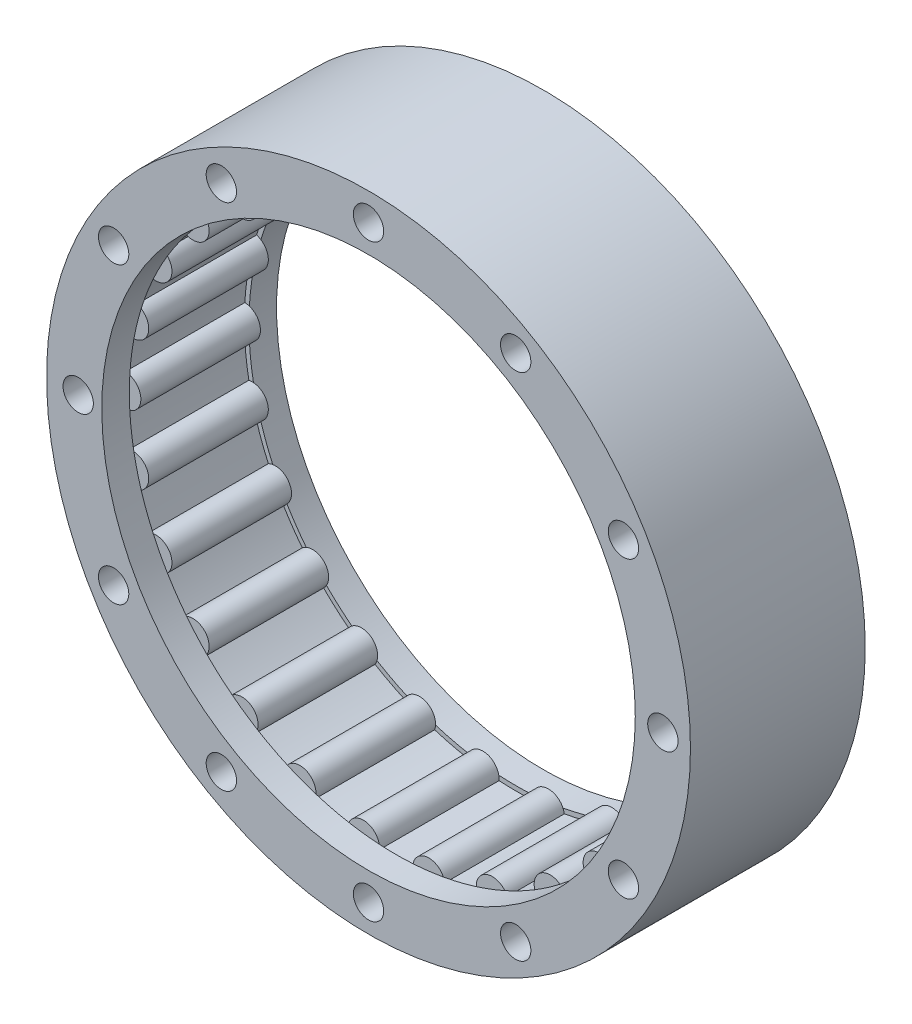
from build123d import *

# Parameters (mm, degrees)
SKETCH_1_R          = 35
SKETCH_1_R_2        = 29.5
EXTRUDE_1_DEPTH     = 13
SKETCH_2_R          = 1.75
EXTRUDE_2_DEPTH     = 13
EXTRUDE_2_2_DEPTH   = 13
EXTRUDE_2_3_DEPTH   = 13
EXTRUDE_2_4_DEPTH   = 13
EXTRUDE_2_5_DEPTH   = 13
EXTRUDE_2_6_DEPTH   = 13
EXTRUDE_2_7_DEPTH   = 13
EXTRUDE_2_8_DEPTH   = 13
EXTRUDE_2_9_DEPTH   = 13
EXTRUDE_2_10_DEPTH  = 13
EXTRUDE_2_11_DEPTH  = 13
EXTRUDE_2_12_DEPTH  = 13
EXTRUDE_2_13_DEPTH  = 13
EXTRUDE_2_14_DEPTH  = 13
EXTRUDE_2_15_DEPTH  = 13
EXTRUDE_2_16_DEPTH  = 13
EXTRUDE_2_17_DEPTH  = 13
EXTRUDE_2_18_DEPTH  = 13
EXTRUDE_2_19_DEPTH  = 13
EXTRUDE_2_20_DEPTH  = 13
EXTRUDE_2_21_DEPTH  = 13
EXTRUDE_2_22_DEPTH  = 13
EXTRUDE_2_23_DEPTH  = 13
EXTRUDE_2_24_DEPTH  = 13
EXTRUDE_2_25_DEPTH  = 13
EXTRUDE_2_26_DEPTH  = 13
SKETCH_14_R         = 35
SKETCH_14_R_2       = 29
EXTRUDE_3_DEPTH     = 3
SKETCH_17_R         = 35
SKETCH_17_R_2       = 29
EXTRUDE_4_DEPTH     = 3
SKETCH_18_R         = 1.65
CUT_EXTRUDE_2_DEPTH = 20


with BuildPart() as part:
    # 草图1 → 凸台-拉伸1 (new body)
    with BuildSketch(Plane.XY):
        Circle(SKETCH_1_R)
        Circle(SKETCH_1_R_2, mode=Mode.SUBTRACT)
    extrude(amount=EXTRUDE_1_DEPTH)



with BuildPart() as body_2:
    # 草图2 → 凸台-拉伸2 (new body)
    with BuildSketch(Plane.XY.offset(13)):
        with Locations((29.5, 0)):
            Circle(SKETCH_2_R)
    extrude(amount=-EXTRUDE_2_DEPTH)


with BuildPart() as body_3:
    # 草图2 → Extrude 2 2 (new body)
    with BuildSketch(Plane.XY.offset(13)):
        with Locations((28.642783614, -7.059812096)):
            Circle(SKETCH_2_R)
    extrude(amount=-EXTRUDE_2_2_DEPTH)


with BuildPart() as body_4:
    # 草图2 → Extrude 2 3 (new body)
    with BuildSketch(Plane.XY.offset(13)):
        with Locations((26.120952757, -13.709333575)):
            Circle(SKETCH_2_R)
    extrude(amount=-EXTRUDE_2_3_DEPTH)


with BuildPart() as body_5:
    # 草图2 → Extrude 2 4 (new body)
    with BuildSketch(Plane.XY.offset(13)):
        with Locations((22.081067071, -19.562118418)):
            Circle(SKETCH_2_R)
    extrude(amount=-EXTRUDE_2_4_DEPTH)


with BuildPart() as body_6:
    # 草图2 → Extrude 2 5 (new body)
    with BuildSketch(Plane.XY.offset(13)):
        with Locations((16.757910029, -24.278024044)):
            Circle(SKETCH_2_R)
    extrude(amount=-EXTRUDE_2_5_DEPTH)


with BuildPart() as body_7:
    # 草图2 → Extrude 2 6 (new body)
    with BuildSketch(Plane.XY.offset(13)):
        with Locations((10.460844168, -27.582979159)):
            Circle(SKETCH_2_R)
    extrude(amount=-EXTRUDE_2_6_DEPTH)


with BuildPart() as body_8:
    # 草图2 → Extrude 2 7 (new body)
    with BuildSketch(Plane.XY.offset(13)):
        with Locations((3.555832068, -29.284911786)):
            Circle(SKETCH_2_R)
    extrude(amount=-EXTRUDE_2_7_DEPTH)


with BuildPart() as body_9:
    # 草图2 → Extrude 2 8 (new body)
    with BuildSketch(Plane.XY.offset(13)):
        with Locations((-3.555832068, -29.284911786)):
            Circle(SKETCH_2_R)
    extrude(amount=-EXTRUDE_2_8_DEPTH)


with BuildPart() as body_10:
    # 草图2 → Extrude 2 9 (new body)
    with BuildSketch(Plane.XY.offset(13)):
        with Locations((-10.460844168, -27.582979159)):
            Circle(SKETCH_2_R)
    extrude(amount=-EXTRUDE_2_9_DEPTH)


with BuildPart() as body_11:
    # 草图2 → Extrude 2 10 (new body)
    with BuildSketch(Plane.XY.offset(13)):
        with Locations((-16.757910029, -24.278024044)):
            Circle(SKETCH_2_R)
    extrude(amount=-EXTRUDE_2_10_DEPTH)


with BuildPart() as body_12:
    # 草图2 → Extrude 2 11 (new body)
    with BuildSketch(Plane.XY.offset(13)):
        with Locations((-22.081067071, -19.562118418)):
            Circle(SKETCH_2_R)
    extrude(amount=-EXTRUDE_2_11_DEPTH)


with BuildPart() as body_13:
    # 草图2 → Extrude 2 12 (new body)
    with BuildSketch(Plane.XY.offset(13)):
        with Locations((-26.120952757, -13.709333575)):
            Circle(SKETCH_2_R)
    extrude(amount=-EXTRUDE_2_12_DEPTH)


with BuildPart() as body_14:
    # 草图2 → Extrude 2 13 (new body)
    with BuildSketch(Plane.XY.offset(13)):
        with Locations((-28.642783614, -7.059812096)):
            Circle(SKETCH_2_R)
    extrude(amount=-EXTRUDE_2_13_DEPTH)


with BuildPart() as body_15:
    # 草图2 → Extrude 2 14 (new body)
    with BuildSketch(Plane.XY.offset(13)):
        with Locations((-29.5, 0)):
            Circle(SKETCH_2_R)
    extrude(amount=-EXTRUDE_2_14_DEPTH)


with BuildPart() as body_16:
    # 草图2 → Extrude 2 15 (new body)
    with BuildSketch(Plane.XY.offset(13)):
        with Locations((-28.642783614, 7.059812096)):
            Circle(SKETCH_2_R)
    extrude(amount=-EXTRUDE_2_15_DEPTH)


with BuildPart() as body_17:
    # 草图2 → Extrude 2 16 (new body)
    with BuildSketch(Plane.XY.offset(13)):
        with Locations((-26.120952757, 13.709333575)):
            Circle(SKETCH_2_R)
    extrude(amount=-EXTRUDE_2_16_DEPTH)


with BuildPart() as body_18:
    # 草图2 → Extrude 2 17 (new body)
    with BuildSketch(Plane.XY.offset(13)):
        with Locations((-22.081067071, 19.562118418)):
            Circle(SKETCH_2_R)
    extrude(amount=-EXTRUDE_2_17_DEPTH)


with BuildPart() as body_19:
    # 草图2 → Extrude 2 18 (new body)
    with BuildSketch(Plane.XY.offset(13)):
        with Locations((-16.757910029, 24.278024044)):
            Circle(SKETCH_2_R)
    extrude(amount=-EXTRUDE_2_18_DEPTH)


with BuildPart() as body_20:
    # 草图2 → Extrude 2 19 (new body)
    with BuildSketch(Plane.XY.offset(13)):
        with Locations((-10.460844168, 27.582979159)):
            Circle(SKETCH_2_R)
    extrude(amount=-EXTRUDE_2_19_DEPTH)


with BuildPart() as body_21:
    # 草图2 → Extrude 2 20 (new body)
    with BuildSketch(Plane.XY.offset(13)):
        with Locations((-3.555832068, 29.284911786)):
            Circle(SKETCH_2_R)
    extrude(amount=-EXTRUDE_2_20_DEPTH)


with BuildPart() as body_22:
    # 草图2 → Extrude 2 21 (new body)
    with BuildSketch(Plane.XY.offset(13)):
        with Locations((3.555832068, 29.284911786)):
            Circle(SKETCH_2_R)
    extrude(amount=-EXTRUDE_2_21_DEPTH)


with BuildPart() as body_23:
    # 草图2 → Extrude 2 22 (new body)
    with BuildSketch(Plane.XY.offset(13)):
        with Locations((10.460844168, 27.582979159)):
            Circle(SKETCH_2_R)
    extrude(amount=-EXTRUDE_2_22_DEPTH)


with BuildPart() as body_24:
    # 草图2 → Extrude 2 23 (new body)
    with BuildSketch(Plane.XY.offset(13)):
        with Locations((16.757910029, 24.278024044)):
            Circle(SKETCH_2_R)
    extrude(amount=-EXTRUDE_2_23_DEPTH)


with BuildPart() as body_25:
    # 草图2 → Extrude 2 24 (new body)
    with BuildSketch(Plane.XY.offset(13)):
        with Locations((22.081067071, 19.562118418)):
            Circle(SKETCH_2_R)
    extrude(amount=-EXTRUDE_2_24_DEPTH)


with BuildPart() as body_26:
    # 草图2 → Extrude 2 25 (new body)
    with BuildSketch(Plane.XY.offset(13)):
        with Locations((26.120952757, 13.709333575)):
            Circle(SKETCH_2_R)
    extrude(amount=-EXTRUDE_2_25_DEPTH)


with BuildPart() as body_27:
    # 草图2 → Extrude 2 26 (new body)
    with BuildSketch(Plane.XY.offset(13)):
        with Locations((28.642783614, 7.059812096)):
            Circle(SKETCH_2_R)
    extrude(amount=-EXTRUDE_2_26_DEPTH)


with BuildPart() as part_1:
    add(part.part)

    add(body_2.part)  # 凸台-拉伸3 merges body 2

    add(body_3.part)  # 凸台-拉伸3 merges body 3

    add(body_4.part)  # 凸台-拉伸3 merges body 4

    add(body_5.part)  # 凸台-拉伸3 merges body 5

    add(body_6.part)  # 凸台-拉伸3 merges body 6

    add(body_7.part)  # 凸台-拉伸3 merges body 7

    add(body_8.part)  # 凸台-拉伸3 merges body 8

    add(body_9.part)  # 凸台-拉伸3 merges body 9

    add(body_10.part)  # 凸台-拉伸3 merges body 10

    add(body_11.part)  # 凸台-拉伸3 merges body 11

    add(body_12.part)  # 凸台-拉伸3 merges body 12

    add(body_13.part)  # 凸台-拉伸3 merges body 13

    add(body_14.part)  # 凸台-拉伸3 merges body 14

    add(body_15.part)  # 凸台-拉伸3 merges body 15

    add(body_16.part)  # 凸台-拉伸3 merges body 16

    add(body_17.part)  # 凸台-拉伸3 merges body 17

    add(body_18.part)  # 凸台-拉伸3 merges body 18

    add(body_19.part)  # 凸台-拉伸3 merges body 19

    add(body_20.part)  # 凸台-拉伸3 merges body 20

    add(body_21.part)  # 凸台-拉伸3 merges body 21

    add(body_22.part)  # 凸台-拉伸3 merges body 22

    add(body_23.part)  # 凸台-拉伸3 merges body 23

    add(body_24.part)  # 凸台-拉伸3 merges body 24

    add(body_25.part)  # 凸台-拉伸3 merges body 25

    add(body_26.part)  # 凸台-拉伸3 merges body 26

    add(body_27.part)  # 凸台-拉伸3 merges body 27
    # 草图14 → 凸台-拉伸3 (add)
    with BuildSketch(Plane.XY):
        Circle(SKETCH_14_R)
        Circle(SKETCH_14_R_2, mode=Mode.SUBTRACT)
    extrude(amount=-EXTRUDE_3_DEPTH)

    # 草图17 → 凸台-拉伸4 (add)
    with BuildSketch(Plane.XY.offset(13)):
        Circle(SKETCH_17_R)
        Circle(SKETCH_17_R_2, mode=Mode.SUBTRACT)
    extrude(amount=EXTRUDE_4_DEPTH)

    # 草图18 → 切除-拉伸2 (cut, through all)
    with BuildSketch(Plane(origin=(0, 0, -3), x_dir=(-1, 0, 0), z_dir=(0, 0, -1))):
        with Locations((31.56394508, 0)):
            Circle(SKETCH_18_R)
        with Locations((27.712812921, -16)):
            Circle(SKETCH_18_R)
        with Locations((16, -27.712812921)):
            Circle(SKETCH_18_R)
        with Locations((0, -32)):
            Circle(SKETCH_18_R)
        with Locations((-16, -27.712812921)):
            Circle(SKETCH_18_R)
        with Locations((-27.712812921, -16)):
            Circle(SKETCH_18_R)
        with Locations((-32, 0)):
            Circle(SKETCH_18_R)
        with Locations((-27.712812921, 16)):
            Circle(SKETCH_18_R)
        with Locations((-16, 27.712812921)):
            Circle(SKETCH_18_R)
        with Locations((0, 32)):
            Circle(SKETCH_18_R)
        with Locations((16, 27.712812921)):
            Circle(SKETCH_18_R)
        with Locations((27.712812921, 16)):
            Circle(SKETCH_18_R)
    extrude(amount=-CUT_EXTRUDE_2_DEPTH, mode=Mode.SUBTRACT)


solid = part_1.part
